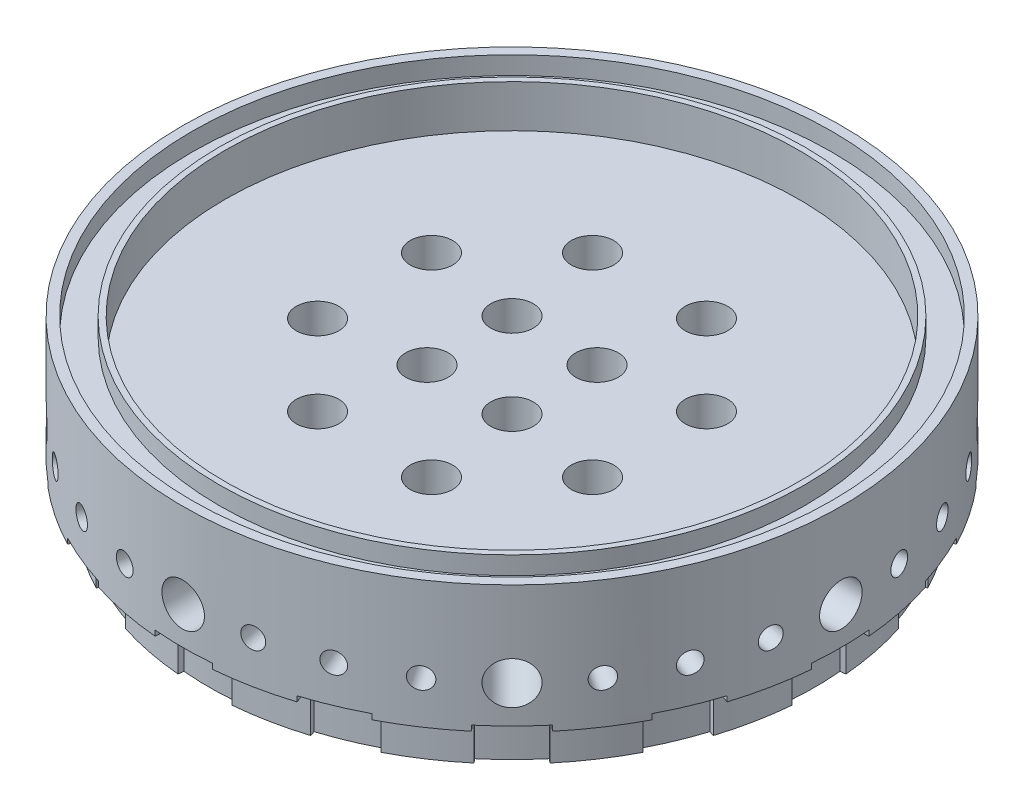
from build123d import *

# Parameters (mm, degrees)
CIRPATTERN9_COUNT  = 32
CIRPATTERN1_COUNT  = 8
CIRPATTERN2_COUNT  = 8
CIRPATTERN3_COUNT  = 4
CIRPATTERN4_COUNT  = 4
CIRPATTERN5_COUNT  = 8
CIRPATTERN7_COUNT  = 4
CIRPATTERN8_COUNT  = 8
CUT_EXTRUDE1_START = -0.79375
CUT_EXTRUDE1_DEPTH = 73.950820589
CIRPATTERN10_COUNT = 16


with BuildPart() as part:
    # Sketch1 → Revolve1 (revolve)
    with BuildSketch(Plane.XY):
        Polygon((0, 0), (-46.0375, 0), (-46.0375, 6.35), (-49.2125, 6.35), (-49.2125, 25.4), (-47.7774, 25.4), (-47.7774, 22.7076), (-43.7134, 22.7076), (-43.7134, 25.4), (-42.8625, 25.4), (-42.8625, 19.05), (0, 19.05), align=None)
    revolve(axis=Axis((0, 19.05, 0), (0, -1, 0)))

    # Sketch37 → 1_8 _0.125_ Diameter Hole2 (revolve, cut)
    with BuildSketch(Plane(origin=(49.2125, 12.7, 0), x_dir=(0, 0, -1), z_dir=(0, 1, 0))):
        Polygon((0, 0), (0, 13.653866233), (1.5875, 12.7), (1.5875, 0), align=None)
    f_1_8_0_125_diameter_hole2 = revolve(axis=Axis((55.5625, 12.7, 0), (-1, 0, 0)), mode=Mode.SUBTRACT)

    # CirPattern9: 1_8 _0.125_ Diameter Hole2 ×32 about axis
    cirpattern9_axis = Axis((0, -42.3, 0), (0, 1, 0))
    for i in range(1, CIRPATTERN9_COUNT):
        add(f_1_8_0_125_diameter_hole2.rotate(cirpattern9_axis, i * 360 / CIRPATTERN9_COUNT), mode=Mode.SUBTRACT)

    # Sketch13 → 1_4 _0.25_ Diameter Hole1 (revolve, cut)
    with BuildSketch(Plane(origin=(49.2125, 12.7, 0), x_dir=(0, 0, -1), z_dir=(0, 1, 0))):
        Polygon((0, 0), (0, 14.607732465), (3.175, 12.7), (3.175, 0), align=None)
    f_1_4_0_25_diameter_hole1 = revolve(axis=Axis((55.5625, 12.7, 0), (-1, 0, 0)), mode=Mode.SUBTRACT)

    # Sketch15 → 3_16 _0.1875_ Diameter Hole1 (revolve, cut)
    with BuildSketch(Plane(origin=(49.2125, 12.7, 0), x_dir=(0, 0, -1), z_dir=(0, 1, 0))):
        Polygon((0, 0), (0, 33.180799349), (2.38125, 31.75), (2.38125, 0), align=None)
    f_3_16_0_1875_diameter_hole1 = revolve(axis=Axis((55.5625, 12.7, 0), (-1, 0, 0)), mode=Mode.SUBTRACT)

    # Sketch17 → 1_8 _0.125_ Diameter Hole1 (revolve, cut)
    with BuildSketch(Plane(origin=(49.2125, 12.7, 0), x_dir=(0, 0, -1), z_dir=(0, 1, 0))):
        Polygon((0, 0), (0, 45.403866233), (1.5875, 44.45), (1.5875, 0), align=None)
    f_1_8_0_125_diameter_hole1 = revolve(axis=Axis((55.5625, 12.7, 0), (-1, 0, 0)), mode=Mode.SUBTRACT)

    # CirPattern1: 1_4 _0.25_ Diameter Hole1 ×8 about axis
    cirpattern1_axis = Axis((0, -42.3, 0), (0, 1, 0))
    for i in range(1, CIRPATTERN1_COUNT):
        add(f_1_4_0_25_diameter_hole1.rotate(cirpattern1_axis, i * 360 / CIRPATTERN1_COUNT), mode=Mode.SUBTRACT)

    # CirPattern2: 3_16 _0.1875_ Diameter Hole1 ×8 about axis
    cirpattern2_axis = Axis((0, -42.3, 0), (0, 1, 0))
    for i in range(1, CIRPATTERN2_COUNT):
        add(f_3_16_0_1875_diameter_hole1.rotate(cirpattern2_axis, i * 360 / CIRPATTERN2_COUNT), mode=Mode.SUBTRACT)

    # CirPattern3: 1_8 _0.125_ Diameter Hole1 ×4 about axis
    cirpattern3_axis = Axis((0, -42.3, 0), (0, 1, 0))
    for i in range(1, CIRPATTERN3_COUNT):
        add(f_1_8_0_125_diameter_hole1.rotate(cirpattern3_axis, i * 360 / CIRPATTERN3_COUNT), mode=Mode.SUBTRACT)

    # Sketch20 → inner large LOX holes (revolve, cut)
    with BuildSketch(Plane(origin=(-6.35, 19.05, 6.35), x_dir=(0, 0, 1), z_dir=(1, 0, 0))):
        Polygon((0, 0), (0, 14.607732465), (3.175, 12.7), (3.175, 0), align=None)
    inner_large_lox_holes = revolve(axis=Axis((-6.35, 25.4, 6.35), (0, -1, 0)), mode=Mode.SUBTRACT)

    # Sketch22 → outer large LOX hole (revolve, cut)
    with BuildSketch(Plane(origin=(-20.53322261, 19.05, 8.505139284), x_dir=(0, 0, 1), z_dir=(1, 0, 0))):
        Polygon((0, 0), (0, 14.607732465), (3.175, 12.7), (3.175, 0), align=None)
    outer_large_lox_hole = revolve(axis=Axis((-20.53322261, 25.4, 8.505139284), (0, -1, 0)), mode=Mode.SUBTRACT)

    # CirPattern4: inner large LOX holes ×4 about axis
    cirpattern4_axis = Axis((0, -42.3, 0), (0, 1, 0))
    for i in range(1, CIRPATTERN4_COUNT):
        add(inner_large_lox_holes.rotate(cirpattern4_axis, i * 360 / CIRPATTERN4_COUNT), mode=Mode.SUBTRACT)

    # CirPattern5: outer large LOX hole ×8 about axis
    cirpattern5_axis = Axis((0, -42.3, 0), (0, 1, 0))
    for i in range(1, CIRPATTERN5_COUNT):
        add(outer_large_lox_hole.rotate(cirpattern5_axis, i * 360 / CIRPATTERN5_COUNT), mode=Mode.SUBTRACT)

    # Sketch28 → 1_16 _0.0625_ Diameter Hole2 (revolve, cut)
    with BuildSketch(Plane(origin=(-6.35, 0, 0), x_dir=(0, 0, -1), z_dir=(1, 0, 0))):
        Polygon((0, 0), (0, 13.176933116), (0.79375, 12.7), (0.79375, 0), align=None)
    f_1_16_0_0625_diameter_hole2 = revolve(axis=Axis((-6.35, -6.35, 0), (0, 1, 0)), mode=Mode.SUBTRACT)

    # Sketch30 → 1_16 _0.0625_ Diameter Hole1 (revolve, cut)
    with BuildSketch(Plane(origin=(-6.35, -6.35, 0), x_dir=(0, 0.500000000000001, -0.866025403784438), z_dir=(1, 0, 0))):
        Polygon((0, 0), (0, 16.097933116), (0.79375, 15.621), (0.79375, 0), align=None)
    f_1_16_0_0625_diameter_hole1 = revolve(axis=Axis((-6.35, -11.849261314, -3.175), (0, 0.866025403784438, 0.500000000000001)), mode=Mode.SUBTRACT)

    # Sketch33 → 1_16 _0.0625_ Diameter Hole3 (revolve, cut)
    with BuildSketch(Plane(origin=(-22.225, 0, 0), x_dir=(0, 0, -1), z_dir=(1, 0, 0))):
        Polygon((0, 0), (0, 13.176933116), (0.79375, 12.7), (0.79375, 0), align=None)
    f_1_16_0_0625_diameter_hole3 = revolve(axis=Axis((-22.225, -6.35, 0), (0, 1, 0)), mode=Mode.SUBTRACT)

    # Sketch35 → 1_16 _0.0625_ Diameter Hole4 (revolve, cut)
    with BuildSketch(Plane(origin=(-22.225, -6.35, 0), x_dir=(0, 0.500000000000001, -0.866025403784438), z_dir=(1, 0, 0))):
        Polygon((0, 0), (0, 19.526933116), (0.79375, 19.05), (0.79375, 0), align=None)
    f_1_16_0_0625_diameter_hole4 = revolve(axis=Axis((-22.225, -11.849261314, -3.175), (0, 0.866025403784438, 0.5000000000000009)), mode=Mode.SUBTRACT)

    # Mirror1: 1_16 _0.0625_ Diameter Hole1 across plane
    add(f_1_16_0_0625_diameter_hole1.mirror(Plane.XY), mode=Mode.SUBTRACT)

    # Mirror2: 1_16 _0.0625_ Diameter Hole4 across plane
    add(f_1_16_0_0625_diameter_hole4.mirror(Plane.XY), mode=Mode.SUBTRACT)

    # CirPattern7: 1_16 _0.0625_ Diameter Hole2, 1_16 _0.0625_ Diameter Hole1 ×4 about axis
    cirpattern7_axis = Axis((0, -42.3, 0), (0, 1, 0))
    add([f_1_16_0_0625_diameter_hole2.rotate(cirpattern7_axis, i * 360 / CIRPATTERN7_COUNT) for i in range(1, CIRPATTERN7_COUNT)], mode=Mode.SUBTRACT)
    add([f_1_16_0_0625_diameter_hole1.rotate(cirpattern7_axis, i * 360 / CIRPATTERN7_COUNT) for i in range(1, CIRPATTERN7_COUNT)], mode=Mode.SUBTRACT)

    # CirPattern7 copy 1 sketch → CirPattern7 copy 1 (revolve, cut)
    with BuildSketch(Plane(origin=(0, -6.35, 6.35), x_dir=(0.866025403784438, 0.500000000000001, 0), z_dir=(0, 0, -1))):
        Polygon((0, 0), (0, -16.097933116), (0.79375, -15.621), (0.79375, 0), align=None)
    revolve(axis=Axis((3.175, -11.849261314, 6.35), (0.500000000000001, -0.866025403784438, 0)), mode=Mode.SUBTRACT)

    # CirPattern7 copy 2 sketch → CirPattern7 copy 2 (revolve, cut)
    with BuildSketch(Plane(origin=(6.35, -6.35, 0), x_dir=(0, 0.500000000000001, -0.866025403784438), z_dir=(-1, 0, 0))):
        Polygon((0, 0), (0, -16.097933116), (0.79375, -15.621), (0.79375, 0), align=None)
    revolve(axis=Axis((6.35, -11.849261314, -3.175), (0, -0.866025403784438, -0.500000000000001)), mode=Mode.SUBTRACT)

    # CirPattern7 copy 3 sketch → CirPattern7 copy 3 (revolve, cut)
    with BuildSketch(Plane(origin=(0, -6.35, -6.35), x_dir=(-0.866025403784438, 0.500000000000001, 0), z_dir=(0, 0, 1))):
        Polygon((0, 0), (0, -16.097933116), (0.79375, -15.621), (0.79375, 0), align=None)
    revolve(axis=Axis((-3.175, -11.849261314, -6.35), (-0.500000000000001, -0.866025403784438, 0)), mode=Mode.SUBTRACT)

    # CirPattern8: 1_16 _0.0625_ Diameter Hole3, 1_16 _0.0625_ Diameter Hole4 ×8 about axis
    cirpattern8_axis = Axis((0, -42.3, 0), (0, 1, 0))
    add([f_1_16_0_0625_diameter_hole3.rotate(cirpattern8_axis, i * 360 / CIRPATTERN8_COUNT) for i in range(1, CIRPATTERN8_COUNT)], mode=Mode.SUBTRACT)
    add([f_1_16_0_0625_diameter_hole4.rotate(cirpattern8_axis, i * 360 / CIRPATTERN8_COUNT) for i in range(1, CIRPATTERN8_COUNT)], mode=Mode.SUBTRACT)

    # CirPattern8 copy 1 sketch → CirPattern8 copy 1 (revolve, cut)
    with BuildSketch(Plane(origin=(-15.715448212, -6.35, 15.715448212), x_dir=(0.612372435695794, 0.500000000000001, 0.6123724356957941), z_dir=(0.7071067811865476, 0, -0.7071067811865475))):
        Polygon((0, 0), (0, -19.526933116), (0.79375, -19.05), (0.79375, 0), align=None)
    revolve(axis=Axis((-13.470384182, -11.849261314, 17.960512242), (0.3535533905932744, -0.866025403784438, 0.35355339059327434)), mode=Mode.SUBTRACT)

    # CirPattern8 copy 2 sketch → CirPattern8 copy 2 (revolve, cut)
    with BuildSketch(Plane(origin=(0, -6.35, 22.225), x_dir=(0.866025403784438, 0.500000000000001, 0), z_dir=(0, 0, -1))):
        Polygon((0, 0), (0, -19.526933116), (0.79375, -19.05), (0.79375, 0), align=None)
    revolve(axis=Axis((3.175, -11.849261314, 22.225), (0.5000000000000009, -0.866025403784438, 0)), mode=Mode.SUBTRACT)

    # CirPattern8 copy 3 sketch → CirPattern8 copy 3 (revolve, cut)
    with BuildSketch(Plane(origin=(15.715448212, -6.35, 15.715448212), x_dir=(0.6123724356957941, 0.500000000000001, -0.612372435695794), z_dir=(-0.7071067811865475, 0, -0.7071067811865476))):
        Polygon((0, 0), (0, -19.526933116), (0.79375, -19.05), (0.79375, 0), align=None)
    revolve(axis=Axis((17.960512242, -11.849261314, 13.470384182), (0.35355339059327434, -0.866025403784438, -0.3535533905932744)), mode=Mode.SUBTRACT)

    # CirPattern8 copy 4 sketch → CirPattern8 copy 4 (revolve, cut)
    with BuildSketch(Plane(origin=(22.225, -6.35, 0), x_dir=(0, 0.500000000000001, -0.866025403784438), z_dir=(-1, 0, 0))):
        Polygon((0, 0), (0, -19.526933116), (0.79375, -19.05), (0.79375, 0), align=None)
    revolve(axis=Axis((22.225, -11.849261314, -3.175), (0, -0.866025403784438, -0.5000000000000009)), mode=Mode.SUBTRACT)

    # CirPattern8 copy 5 sketch → CirPattern8 copy 5 (revolve, cut)
    with BuildSketch(Plane(origin=(15.715448212, -6.35, -15.715448212), x_dir=(-0.612372435695794, 0.500000000000001, -0.6123724356957942), z_dir=(-0.7071067811865477, 0, 0.7071067811865475))):
        Polygon((0, 0), (0, -19.526933116), (0.79375, -19.05), (0.79375, 0), align=None)
    revolve(axis=Axis((13.470384182, -11.849261314, -17.960512242), (-0.3535533905932744, -0.866025403784438, -0.3535533905932744)), mode=Mode.SUBTRACT)

    # CirPattern8 copy 6 sketch → CirPattern8 copy 6 (revolve, cut)
    with BuildSketch(Plane(origin=(0, -6.35, -22.225), x_dir=(-0.866025403784438, 0.500000000000001, 0), z_dir=(0, 0, 1))):
        Polygon((0, 0), (0, -19.526933116), (0.79375, -19.05), (0.79375, 0), align=None)
    revolve(axis=Axis((-3.175, -11.849261314, -22.225), (-0.5000000000000009, -0.866025403784438, 0)), mode=Mode.SUBTRACT)

    # CirPattern8 copy 7 sketch → CirPattern8 copy 7 (revolve, cut)
    with BuildSketch(Plane(origin=(-15.715448212, -6.35, -15.715448212), x_dir=(-0.6123724356957942, 0.500000000000001, 0.6123724356957939), z_dir=(0.7071067811865474, 0, 0.7071067811865477))):
        Polygon((0, 0), (0, -19.526933116), (0.79375, -19.05), (0.79375, 0), align=None)
    revolve(axis=Axis((-17.960512242, -11.849261314, -13.470384182), (-0.3535533905932744, -0.866025403784438, 0.35355339059327434)), mode=Mode.SUBTRACT)

    # Sketch38 → Cut-Extrude1 (cut)
    with BuildSketch(Plane.XZ.offset(-6.35).offset(CUT_EXTRUDE1_START)):
        with BuildLine():
            Line((45.071583872, -3.943252636), (49.02523158, -4.28915199))
            ThreePointArc((49.02523158, -4.28915199), (49.2125, 0), (49.02523158, 4.28915199))
            Line((49.02523158, 4.28915199), (45.071583872, 3.943252636))
            ThreePointArc((45.071583872, 3.943252636), (45.24375, 0), (45.071583872, -3.943252636))
        make_face()
    cut_extrude1 = extrude(amount=CUT_EXTRUDE1_DEPTH, mode=Mode.SUBTRACT)

    # CirPattern10: Cut-Extrude1 ×16 about axis
    cirpattern10_axis = Axis((0, 19.05, 0), (0, 1, 0))
    for i in range(1, CIRPATTERN10_COUNT):
        add(cut_extrude1.rotate(cirpattern10_axis, i * 360 / CIRPATTERN10_COUNT), mode=Mode.SUBTRACT)


solid = part.part
